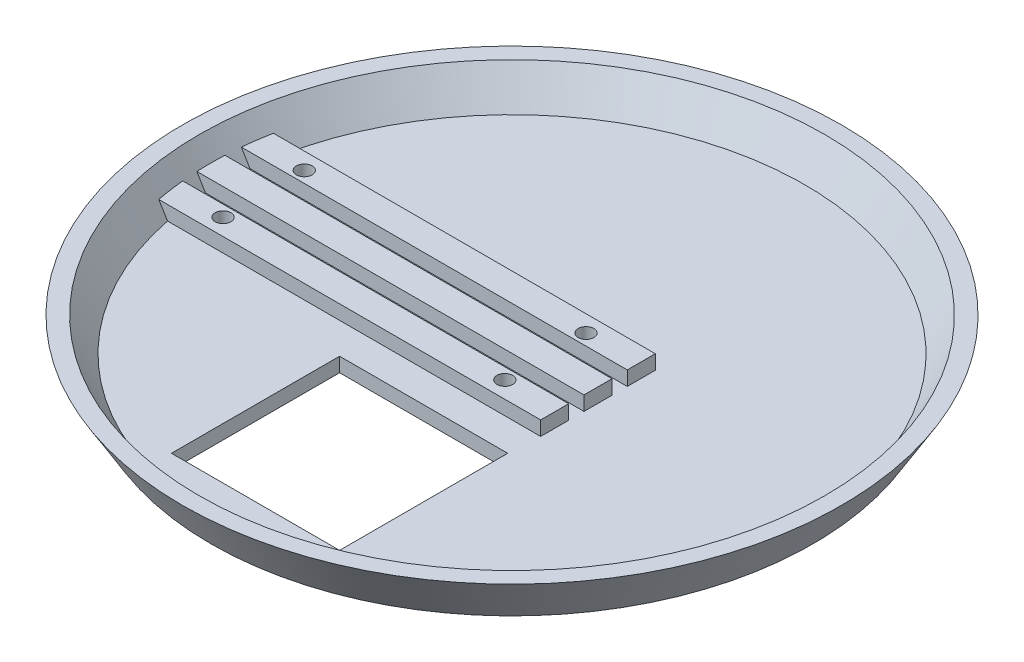
from build123d import *

# Parameters (mm, degrees)
SKETCH2_W                = 35.2
SKETCH2_H                = 35.2
CUT_EXTRUDE1_DEPTH       = 4
SKETCH4_W                = 5.866666667
SKETCH4_H                = 3
SKETCH4_W_2              = 5.866666666
BOSS_EXTRUDE1_DEPTH      = 10
BOSS_EXTRUDE1_DEPTH_BACK = 63.5
SKETCH5_R                = 1.65
CUT_EXTRUDE2_DEPTH       = 11
SKETCH8_W                = 5.866666667
SKETCH8_H                = 3
SKETCH8_W_2              = 5.866666666
BOSS_EXTRUDE3_DEPTH      = 8


with BuildPart() as part:
    # Sketch1 → Revolve1 (revolve)
    with BuildSketch(Plane.XY):
        Polygon((0, 0), (63, 0), (69, 10), (65.501428863, 10), (61.301428863, 3), (0, 3), align=None)
    revolve(axis=Axis((0, 0, 0), (0, 1, 0)))

    # Sketch2 → Cut-Extrude1 (cut, through all)
    with BuildSketch(Plane(origin=(0, 3, 0), x_dir=(1, 0, 0), z_dir=(0, 1, 0))):
        with Locations((0, -36.1)):
            Rectangle(SKETCH2_W, SKETCH2_H)
    extrude(amount=-CUT_EXTRUDE1_DEPTH, mode=Mode.SUBTRACT)

    # Sketch4 → Boss-Extrude1 (add, two sides)
    with BuildSketch(Plane(origin=(0, 0, 0), x_dir=(0, 0, -1), z_dir=(1, 0, 0))) as boss_extrude1_sk:
        with Locations((-9.066666666, 4.5)):
            Rectangle(SKETCH4_W, SKETCH4_H)
        with Locations((0, 4.5)):
            Rectangle(SKETCH4_W_2, SKETCH4_H)
        with Locations((9.066666666, 4.5)):
            Rectangle(SKETCH4_W, SKETCH4_H)
    extrude(amount=BOSS_EXTRUDE1_DEPTH)
    extrude(boss_extrude1_sk.sketch, amount=-BOSS_EXTRUDE1_DEPTH_BACK)

    # Sketch5 → Cut-Extrude2 (cut, through all)
    with BuildSketch(Plane(origin=(0, 0, 0), x_dir=(1, 0, 0), z_dir=(0, 1, 0))):
        with Locations((7, -8.5)):
            Circle(SKETCH5_R)
        with Locations((7, 8.5)):
            Circle(SKETCH5_R)
        with Locations((-52, 8.5)):
            Circle(SKETCH5_R)
        with Locations((-52, -8.5)):
            Circle(SKETCH5_R)
    extrude(amount=CUT_EXTRUDE2_DEPTH, mode=Mode.SUBTRACT)

    # Sketch8 → Boss-Extrude3 (add)
    with BuildSketch(Plane(origin=(10, 0, 0), x_dir=(0, 0, -1), z_dir=(1, 0, 0))):
        with Locations((-9.066666666, 4.5)):
            Rectangle(SKETCH8_W, SKETCH8_H)
        with Locations((0, 4.5)):
            Rectangle(SKETCH8_W_2, SKETCH8_H)
        with Locations((9.066666666, 4.5)):
            Rectangle(SKETCH8_W, SKETCH8_H)
    extrude(amount=BOSS_EXTRUDE3_DEPTH)


solid = part.part
